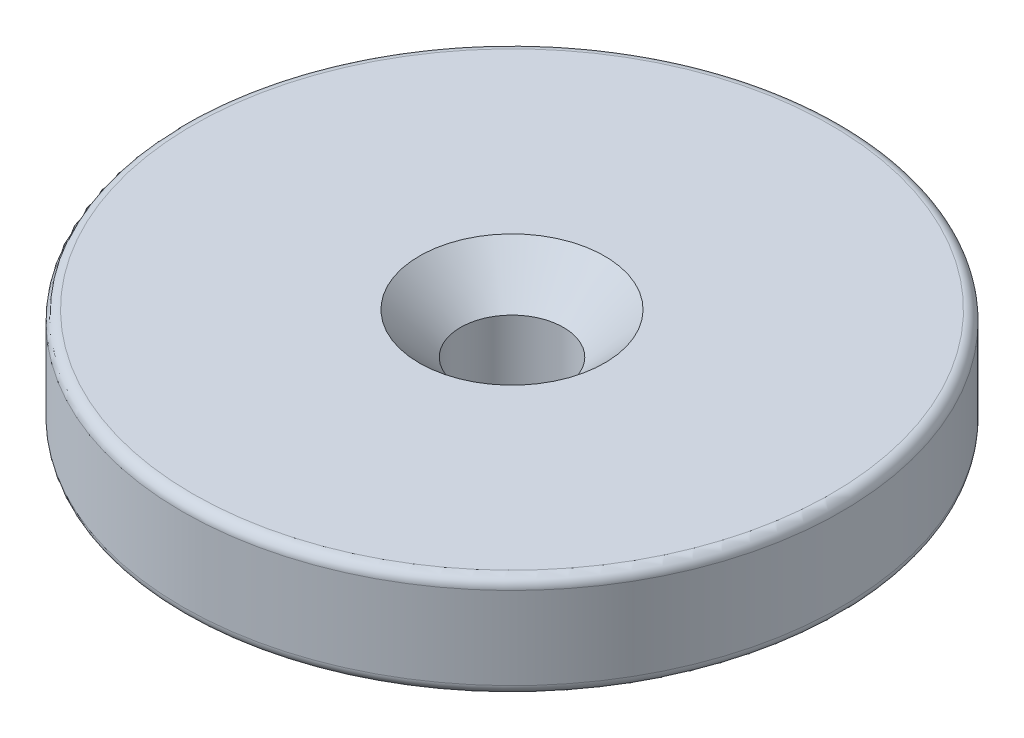
from build123d import *

# Parameters (mm, degrees)
SKETCH1_R           = 16
SKETCH1_R_2         = 2.5
BOSS_EXTRUDE1_DEPTH = 5
CHAMFER1_SIZE       = 2
FILLET1_R           = 0.5


with BuildPart() as part:
    # Sketch1 → Boss-Extrude1 (new body)
    with BuildSketch(Plane(origin=(0, 0, 0), x_dir=(1, 0, 0), z_dir=(0, 1, 0))):
        Circle(SKETCH1_R)
        Circle(SKETCH1_R_2, mode=Mode.SUBTRACT)
    extrude(amount=BOSS_EXTRUDE1_DEPTH)

    # Chamfer1
    chamfer1_edges = [part.edges().sort_by_distance(p)[0] for p in [
        (-2.5, 5, 0),
    ]]
    chamfer(chamfer1_edges, length=CHAMFER1_SIZE)

    # Fillet1
    fillet1_edges = [part.edges().sort_by_distance(p)[0] for p in [
        (-16, 0, 0),
        (-16, 5, 0),
    ]]
    fillet(fillet1_edges, radius=FILLET1_R)


solid = part.part
